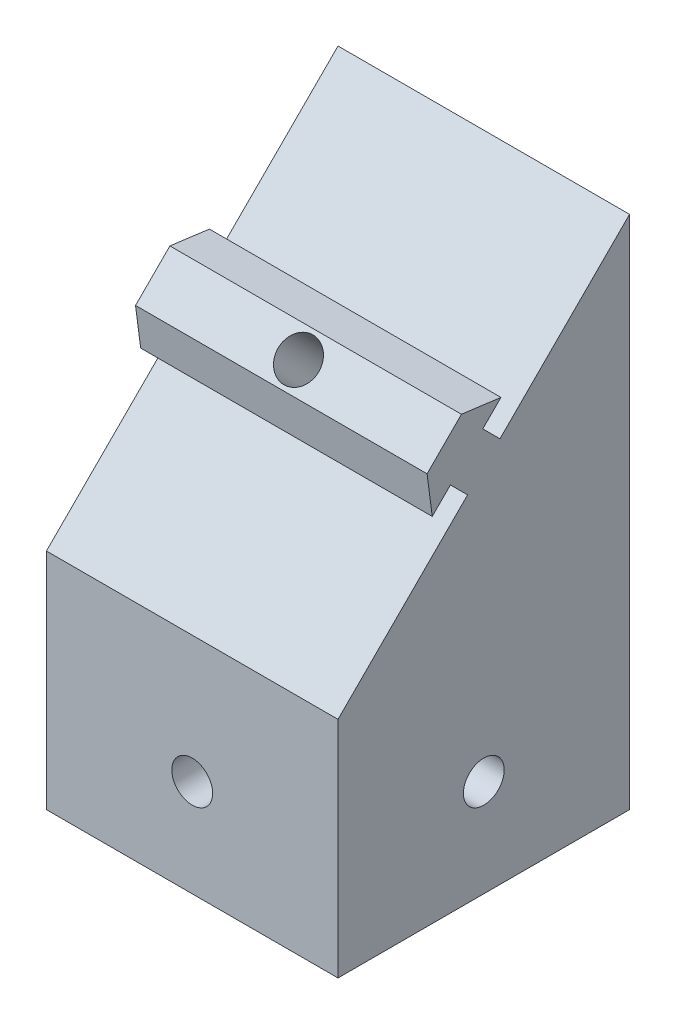
from build123d import *

# Parameters (mm, degrees)
SKETCH1_W           = 30
SKETCH1_H           = 30
SKETCH1_W_2         = 20
SKETCH1_H_2         = 20
BOSS_EXTRUDE1_DEPTH = 20
SKETCH2_W           = 4.711017494
SKETCH2_H           = 2
SKETCH2_W_2         = 2
SKETCH2_H_2         = 4.711017494
BOSS_EXTRUDE2_DEPTH = 20
SKETCH3_R           = 2.1
CUT_EXTRUDE1_DEPTH  = 31
SKETCH4_R           = 2.1
CUT_EXTRUDE2_DEPTH  = 31
BOSS_EXTRUDE3_DEPTH = 30
SKETCH8_W           = 4.711017494
SKETCH8_H           = 2.5
BOSS_EXTRUDE4_DEPTH = 30
SKETCH10_R          = 2.1
CUT_EXTRUDE4_DEPTH  = 44.261940705


with BuildPart() as part:
    # Sketch1 → Boss-Extrude1 (new body)
    with BuildSketch(Plane(origin=(0, 0, 0), x_dir=(1, 0, 0), z_dir=(0, 1, 0))):
        Rectangle(SKETCH1_W, SKETCH1_H)
        Rectangle(SKETCH1_W_2, SKETCH1_H_2, mode=Mode.SUBTRACT)
    extrude(amount=BOSS_EXTRUDE1_DEPTH)


with BuildPart() as body_2:
    # Sketch2 → Boss-Extrude2 (new body)
    with BuildSketch(Plane(origin=(0, 20, 0), x_dir=(1, 0, 0), z_dir=(0, 1, 0))):
        Polygon((2.336539675, 4), (-2.663460325, 4), (-4.950152781, 8), (5.049847219, 8), align=None)
        with Locations((0, 9)):
            Rectangle(SKETCH2_W, SKETCH2_H)
        Polygon((-4, 2.336539675), (-4, -2.663460325), (-8, -4.950152781), (-8, 5.049847219), align=None)
        Polygon((-2.336539675, -4), (2.663460325, -4), (4.950152781, -8), (-5.049847219, -8), align=None)
        with Locations((0, -9)):
            Rectangle(SKETCH2_W, SKETCH2_H)
        Polygon((4, 2.663460325), (4, -2.336539675), (8, -5.049847219), (8, -2.355508747), (8, 2.355508747), (8, 4.950152781), align=None)
        with Locations((9, 0)):
            Rectangle(SKETCH2_W_2, SKETCH2_H_2)
        with Locations((-9, 0)):
            Rectangle(SKETCH2_W_2, SKETCH2_H_2)
    extrude(amount=-BOSS_EXTRUDE2_DEPTH)


with BuildPart() as cut_extrude1_tool:
    # Sketch3 → Cut-Extrude1 (new body, through all)
    with BuildSketch(Plane.ZY.offset(15)):
        with Locations((0, 10)):
            Circle(SKETCH3_R)
    extrude(amount=-CUT_EXTRUDE1_DEPTH)


with BuildPart() as part_1:
    add(part.part)

    # Cut-Extrude1: cut by cut_extrude1_tool
    add(cut_extrude1_tool.part, mode=Mode.SUBTRACT)


with BuildPart() as body_2_1:
    add(body_2.part)

    # Cut-Extrude1: cut by cut_extrude1_tool
    add(cut_extrude1_tool.part, mode=Mode.SUBTRACT)


with BuildPart() as cut_extrude2_tool:
    # Sketch4 → Cut-Extrude2 (new body, through all)
    with BuildSketch(Plane(origin=(0, 0, -15), x_dir=(-1, 0, 0), z_dir=(0, 0, -1))):
        with Locations((0, 10)):
            Circle(SKETCH4_R)
    extrude(amount=-CUT_EXTRUDE2_DEPTH)


with BuildPart() as part_2:
    add(part_1.part)

    # Cut-Extrude2: cut by cut_extrude2_tool
    add(cut_extrude2_tool.part, mode=Mode.SUBTRACT)



with BuildPart() as body_2_2:
    add(body_2_1.part)

    # Cut-Extrude2: cut by cut_extrude2_tool
    add(cut_extrude2_tool.part, mode=Mode.SUBTRACT)


with BuildPart() as part_3:
    add(part_2.part)

    add(body_2_2.part)  # Boss-Extrude3 merges body 2
    # Sketch5 → Boss-Extrude3 (add)
    with BuildSketch(Plane(origin=(15, 0, 0), x_dir=(0, 0, -1), z_dir=(1, 0, 0))):
        Polygon((15, 53.049895295), (15, 50), (-15, 20), (-15, 23.049895295), align=None)
        Polygon((15, 50), (-15, 20), (15, 20), align=None)
    extrude(amount=-BOSS_EXTRUDE3_DEPTH)

    # Sketch8 → Boss-Extrude4 (add)
    with BuildSketch(Plane(origin=(15, 0, 0), x_dir=(0, 0.707106781, -0.707106781), z_dir=(1, 0, 0))):
        Polygon((29.405338987, 32.655338987), (24.405338987, 32.655338987), (21.905338989, 29.405338987), (24.54983024, 29.405338987), (29.260847734, 29.405338987), (31.905338989, 29.405338987), align=None)
        with Locations((26.905338987, 28.155338987)):
            Rectangle(SKETCH8_W, SKETCH8_H)
    extrude(amount=-BOSS_EXTRUDE4_DEPTH)

    # Sketch10 → Cut-Extrude4 (cut, through all)
    with BuildSketch(Plane(origin=(0, 23.090811639, 23.090811639), x_dir=(1, 0, 0), z_dir=(0, 0.707106781, 0.707106781))):
        with Locations((0, 26.905338987)):
            Circle(SKETCH10_R)
    extrude(amount=-CUT_EXTRUDE4_DEPTH, mode=Mode.SUBTRACT)


solid = part_3.part
